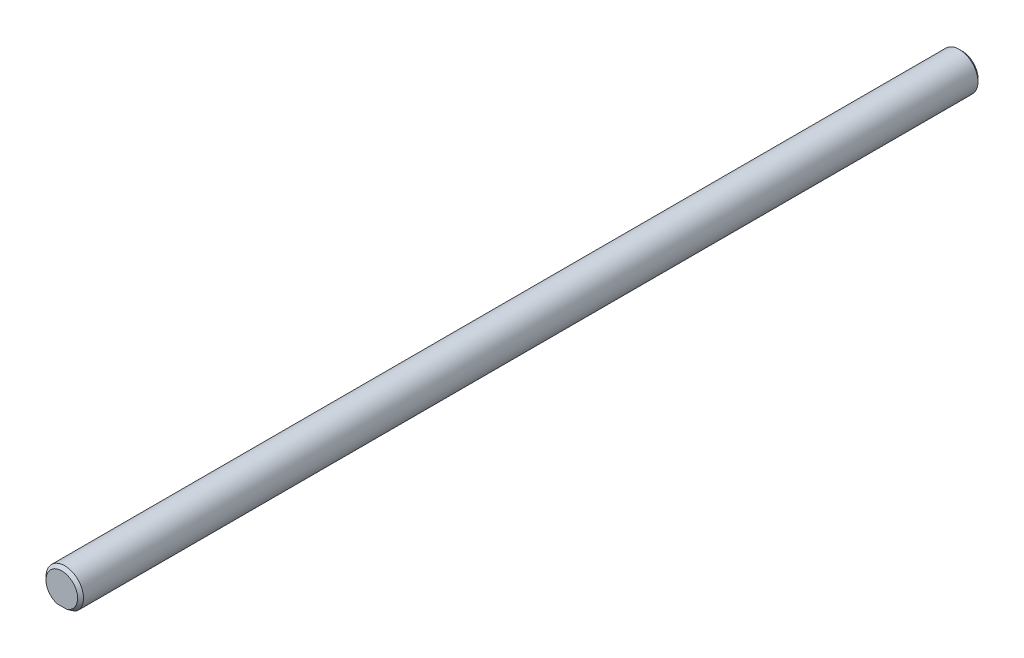
from build123d import *

# Parameters (mm, degrees)
CHAMFER1_SIZE = 0.5


with BuildPart() as part:
    # Sweep1: sweep along a path in Sketch2
    with BuildLine(Plane(origin=(0, 0, 0), x_dir=(1, 0, 0), z_dir=(0, 1, 0))) as sweep1_path:
        Line((0, -76.2), (0, 76.2))
    # Sketch1 → Sweep1 (sweep)
    with BuildSketch(Plane.XY):
        with BuildLine():
            Line((-1.905, -2.54), (1.905, -2.54))
            ThreePointArc((1.905, -2.54), (0, 3.175), (-1.905, -2.54))
        make_face()
    sweep(path=sweep1_path.line)

    # Chamfer1
    chamfer1_edges = [part.edges().sort_by_distance(p)[0] for p in [
        (0, 3.175, -76.2),
        (0, 3.175, 76.2),
    ]]
    chamfer(chamfer1_edges, length=CHAMFER1_SIZE)


solid = part.part
